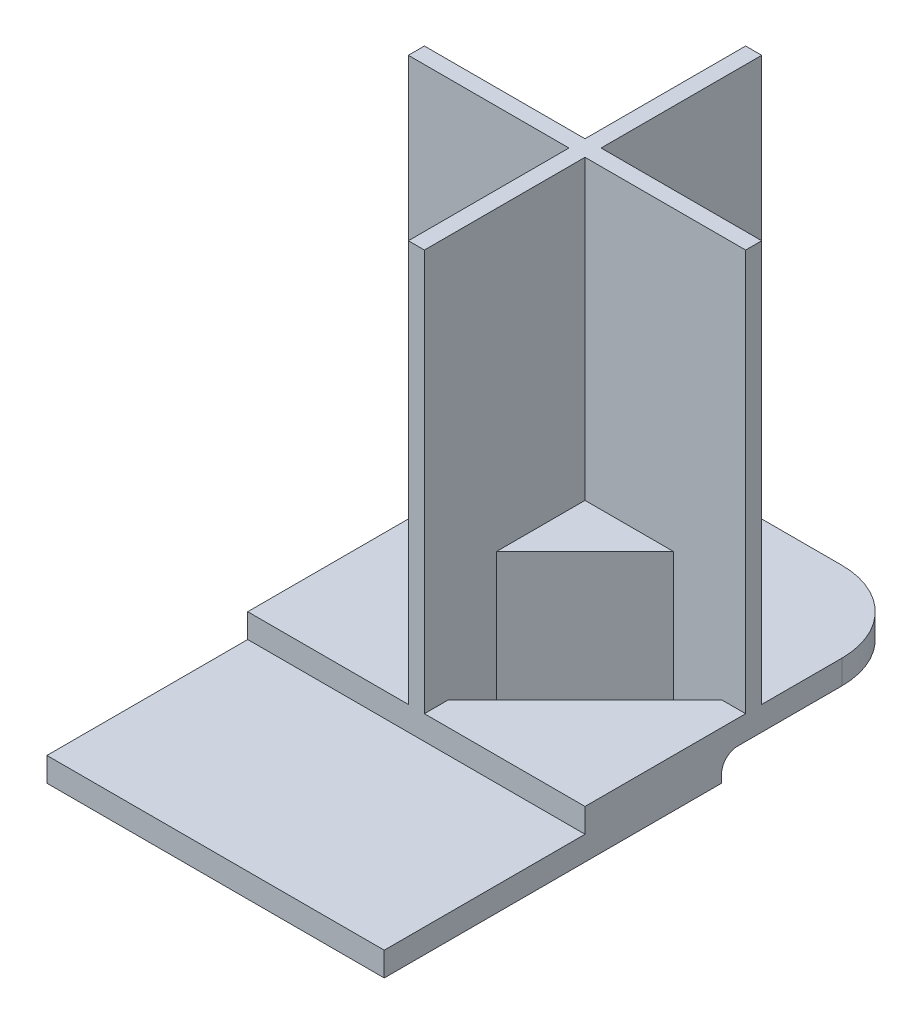
from build123d import *

# Parameters (mm, degrees)
SKETCH1_W           = 42
SKETCH1_H           = 25
BOSS_EXTRUDE1_DEPTH = 3
SKETCH2_W           = 42
SKETCH2_H           = 17
BOSS_EXTRUDE2_DEPTH = 6
SKETCH4_W           = 42
SKETCH4_H           = 3
BOSS_EXTRUDE4_DEPTH = 3
FILLET2_R           = 2
SKETCH5_W           = 42
SKETCH5_H           = 3
BOSS_EXTRUDE5_DEPTH = 2
SKETCH7_W           = 42
SKETCH7_H           = 3
BOSS_EXTRUDE6_DEPTH = 20
BOSS_EXTRUDE7_DEPTH = 50
BOSS_EXTRUDE8_DEPTH = 13
CUT_EXTRUDE1_DEPTH  = 13
FILLET3_R           = 10


with BuildPart() as part:
    # Sketch1 → Boss-Extrude1 (new body)
    with BuildSketch(Plane(origin=(0, 0, 0), x_dir=(1, 0, 0), z_dir=(0, 1, 0))):
        Rectangle(SKETCH1_W, SKETCH1_H)
    extrude(amount=BOSS_EXTRUDE1_DEPTH)

    # Sketch2 → Boss-Extrude2 (add)
    with BuildSketch(Plane(origin=(0, 0, 0), x_dir=(1, 0, 0), z_dir=(0, 1, 0))):
        with Locations((0, 21)):
            Rectangle(SKETCH2_W, SKETCH2_H)
    extrude(amount=BOSS_EXTRUDE2_DEPTH)

    # Sketch4 → Boss-Extrude4 (add)
    with BuildSketch(Plane(origin=(0, 0, -29.5), x_dir=(-1, 0, 0), z_dir=(0, 0, -1))):
        with Locations((0, 4.5)):
            Rectangle(SKETCH4_W, SKETCH4_H)
    extrude(amount=BOSS_EXTRUDE4_DEPTH)

    # Fillet2
    fillet2_edges = [part.edges().sort_by_distance(p)[0] for p in [
        (0, 3, -29.5),
    ]]
    fillet(fillet2_edges, radius=FILLET2_R)

    # Sketch5 → Boss-Extrude5 (add)
    with BuildSketch(Plane(origin=(0, 0, -32.5), x_dir=(-1, 0, 0), z_dir=(0, 0, -1))):
        with Locations((0, 4.5)):
            Rectangle(SKETCH5_W, SKETCH5_H)
    extrude(amount=BOSS_EXTRUDE5_DEPTH)

    # Sketch7 → Boss-Extrude6 (add)
    with BuildSketch(Plane(origin=(0, 0, -34.5), x_dir=(-1, 0, 0), z_dir=(0, 0, -1))):
        with Locations((0, 4.5)):
            Rectangle(SKETCH7_W, SKETCH7_H)
    extrude(amount=BOSS_EXTRUDE6_DEPTH)

    # Sketch6 → Boss-Extrude7 (add)
    with BuildSketch(Plane(origin=(0, 6, 0), x_dir=(1, 0, 0), z_dir=(0, 1, 0))):
        Polygon((-21, 34.5), (-1, 34.5), (-1, 54.5), (1, 54.5), (1, 34.5), (21, 34.5), (21, 32.5), (1, 32.5), (1, 12.5), (-1, 12.5), (-1, 32.5), (-21, 32.5), align=None)
    extrude(amount=BOSS_EXTRUDE7_DEPTH)

    # Sketch9 → Boss-Extrude8 (add)
    with BuildSketch(Plane(origin=(0, 6, 0), x_dir=(1, 0, 0), z_dir=(0, 1, 0))):
        Polygon((-12, 34.5), (-1, 45.5), (-1, 34.5), align=None)
        Polygon((1, 34.5), (1, 45.5), (12, 34.5), align=None)
        Polygon((12, 32.5), (1, 32.5), (1, 21.5), align=None)
        Polygon((-1, 21.5), (-1, 32.5), (-12, 32.5), align=None)
    extrude(amount=BOSS_EXTRUDE8_DEPTH)

    # Sketch10 → Cut-Extrude1 (cut)
    with BuildSketch(Plane(origin=(0, 6, 0), x_dir=(1, 0, 0), z_dir=(0, 1, 0))):
        Polygon((1, 45.5), (1, 51.581118318), (18.081118318, 34.5), (12, 34.5), align=None)
        Polygon((-1, 45.5), (-1, 51.581118318), (-18.081118318, 34.5), (-12, 34.5), align=None)
        Polygon((-12, 32.5), (-1, 21.5), (-1, 15.418881682), (-18.081118318, 32.5), align=None)
        Polygon((1, 21.5), (1, 15.418881682), (18.081118318, 32.5), (12, 32.5), align=None)
    extrude(amount=-CUT_EXTRUDE1_DEPTH, mode=Mode.SUBTRACT)

    # Fillet3
    fillet3_edges = [part.edges().sort_by_distance(p)[0] for p in [
        (21, 4.5, -54.5),
        (-21, 4.5, -54.5),
    ]]
    fillet(fillet3_edges, radius=FILLET3_R)


solid = part.part
